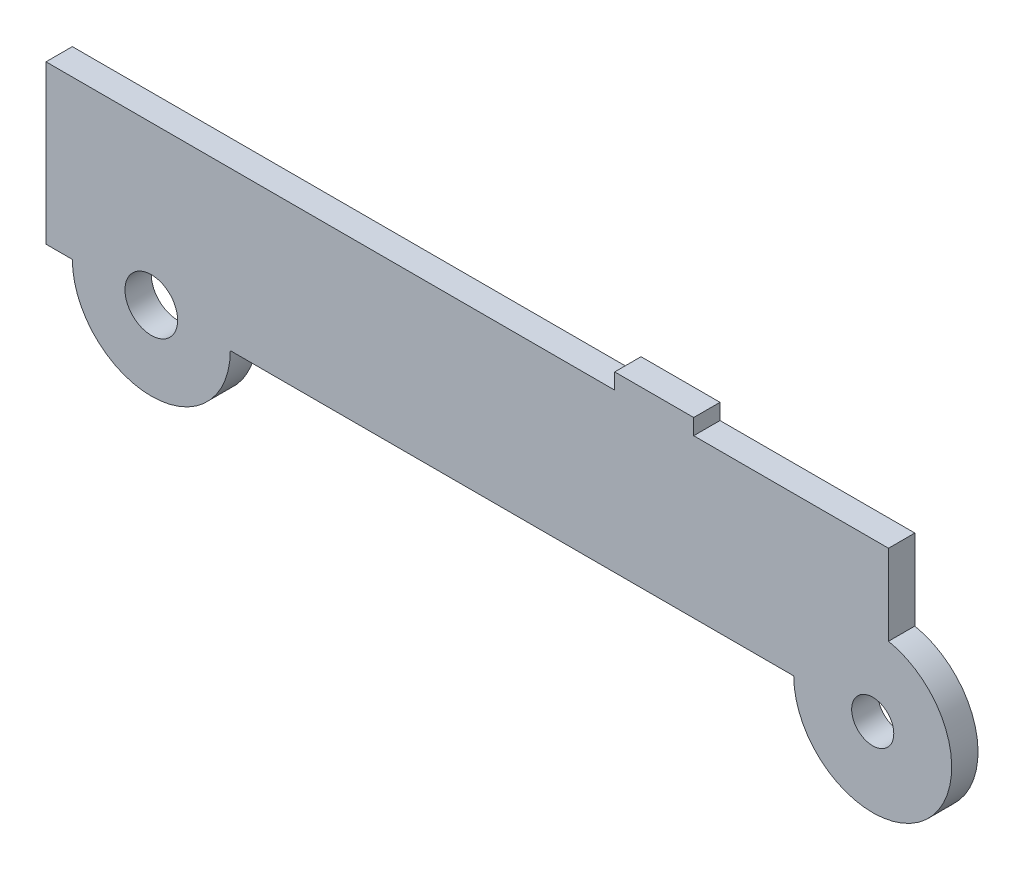
from build123d import *

# Parameters (mm, degrees)
SKETCH_1_W          = 160
SKETCH_1_H          = 30
EXTRUDE_1_DEPTH     = 5
SKETCH_2_R          = 15
EXTRUDE_2_DEPTH     = 5
SKETCH_3_R          = 5
SKETCH_3_R_2        = 4
CUT_EXTRUDE_1_DEPTH = 6
SKETCH_4_W          = 15
SKETCH_4_H          = 5
EXTRUDE_3_DEPTH     = 3


with BuildPart() as part:
    # 草图1 → 凸台-拉伸1 (new body)
    with BuildSketch(Plane.XY):
        Rectangle(SKETCH_1_W, SKETCH_1_H)
    extrude(amount=EXTRUDE_1_DEPTH)

    # 草图2 → 凸台-拉伸2 (add)
    with BuildSketch(Plane.XY.offset(5)):
        with Locations((-60, -15)):
            Circle(SKETCH_2_R)
        with Locations((77, -15)):
            Circle(SKETCH_2_R)
    extrude(amount=-EXTRUDE_2_DEPTH)

    # 草图3 → 切除-拉伸1 (cut, through all)
    with BuildSketch(Plane.XY.offset(5)):
        with Locations((-60, -15)):
            Circle(SKETCH_3_R)
        with Locations((77, -15)):
            Circle(SKETCH_3_R_2)
    extrude(amount=-CUT_EXTRUDE_1_DEPTH, mode=Mode.SUBTRACT)

    # 草图4 → 凸台-拉伸3 (add)
    with BuildSketch(Plane(origin=(0, 15, 0), x_dir=(1, 0, 0), z_dir=(0, 1, 0))):
        with Locations((35.5, -2.5)):
            Rectangle(SKETCH_4_W, SKETCH_4_H)
    extrude(amount=EXTRUDE_3_DEPTH)


solid = part.part
